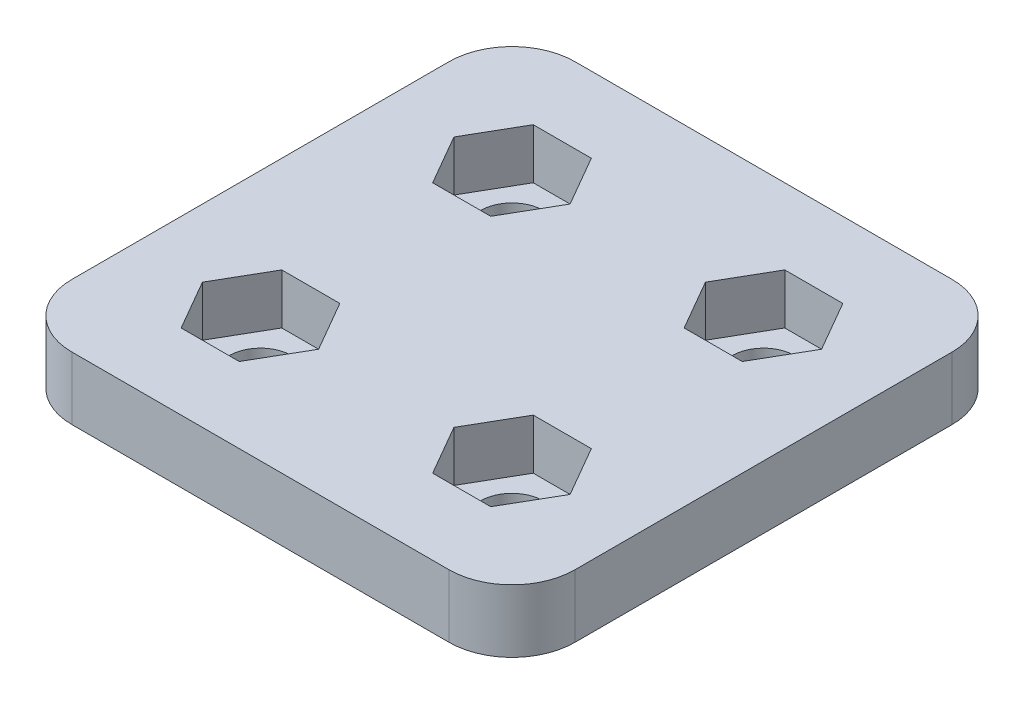
from build123d import *

# Parameters (mm, degrees)
SKETCH1_W           = 40
SKETCH1_H           = 40
BOSS_EXTRUDE1_DEPTH = 5
CUT_EXTRUDE1_DEPTH  = 4
SKETCH3_R           = 2.5
CUT_EXTRUDE2_DEPTH  = 2
FILLET1_R           = 5


with BuildPart() as part:
    # Sketch1 → Boss-Extrude1 (new body)
    with BuildSketch(Plane(origin=(0, 0, 0), x_dir=(1, 0, 0), z_dir=(0, 1, 0))):
        Rectangle(SKETCH1_W, SKETCH1_H)
    extrude(amount=BOSS_EXTRUDE1_DEPTH)

    # Sketch2 → Cut-Extrude1 (cut)
    with BuildSketch(Plane(origin=(0, 5, 0), x_dir=(1, 0, 0), z_dir=(0, 1, 0))):
        Polygon((-5.381197846, 10), (-7.690598923, 14), (-12.309401077, 14), (-14.618802154, 10), (-12.309401077, 6), (-7.690598923, 6), align=None)
        Polygon((14.618802154, 10), (12.309401077, 14), (7.690598923, 14), (5.381197846, 10), (7.690598923, 6), (12.309401077, 6), align=None)
        Polygon((-5.381197846, -10), (-7.690598923, -6), (-12.309401077, -6), (-14.618802154, -10), (-12.309401077, -14), (-7.690598923, -14), align=None)
        Polygon((14.618802154, -10), (12.309401077, -6), (7.690598923, -6), (5.381197846, -10), (7.690598923, -14), (12.309401077, -14), align=None)
    extrude(amount=-CUT_EXTRUDE1_DEPTH, mode=Mode.SUBTRACT)

    # Sketch3 → Cut-Extrude2 (cut, through all)
    with BuildSketch(Plane(origin=(0, 1, 0), x_dir=(1, 0, 0), z_dir=(0, 1, 0))):
        with Locations((-10, 10)):
            Circle(SKETCH3_R)
        with Locations((10, 10)):
            Circle(SKETCH3_R)
        with Locations((-10, -10)):
            Circle(SKETCH3_R)
        with Locations((10, -10)):
            Circle(SKETCH3_R)
    extrude(amount=-CUT_EXTRUDE2_DEPTH, mode=Mode.SUBTRACT)

    # Fillet1
    fillet1_edges = [part.edges().sort_by_distance(p)[0] for p in [
        (20, 2.5, 20),
        (-20, 2.5, 20),
        (-20, 2.5, -20),
        (20, 2.5, -20),
    ]]
    fillet(fillet1_edges, radius=FILLET1_R)


solid = part.part
